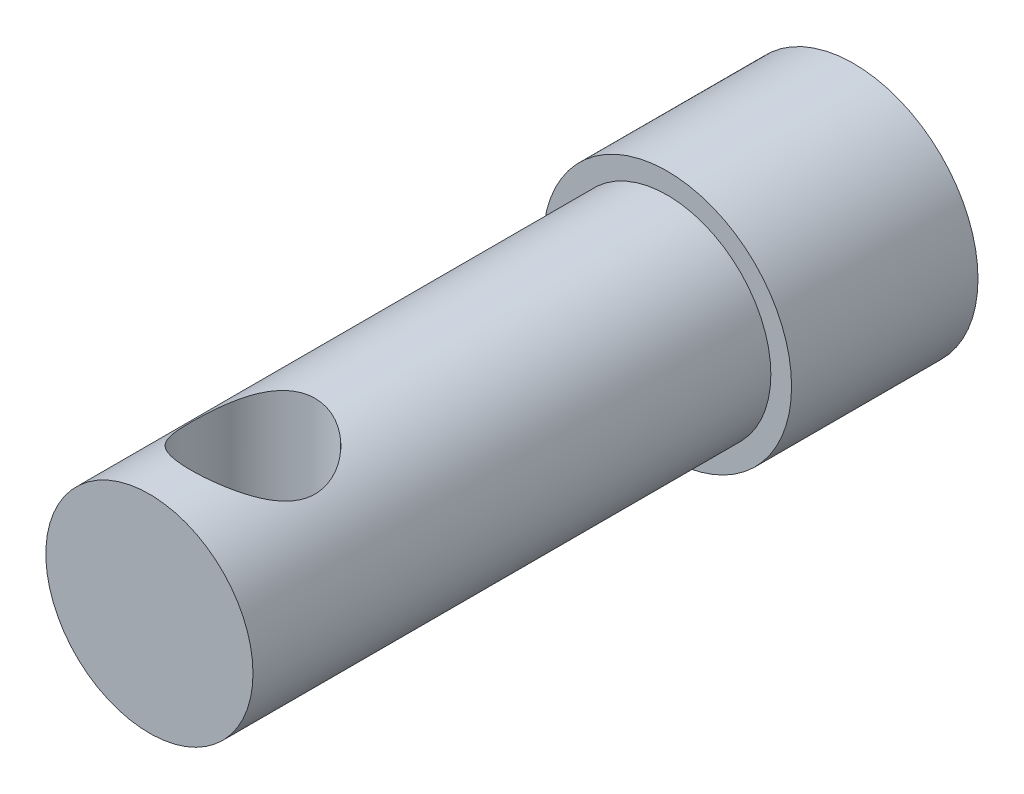
from build123d import *

# Parameters (mm, degrees)
SKETCH_1_R          = 5
EXTRUDE_1_DEPTH     = 34
SKETCH_4_R          = 6
EXTRUDE_2_DEPTH     = 9
CUT_EXTRUDE_1_DEPTH = 8
SKETCH_3_R          = 3
CUT_EXTRUDE_2_DEPTH = 12


with BuildPart() as part:
    # 草图1 → 凸台-拉伸1 (new body)
    with BuildSketch(Plane.XY):
        Circle(SKETCH_1_R)
    extrude(amount=EXTRUDE_1_DEPTH)

    # 草图4 → 凸台-拉伸2 (add)
    with BuildSketch(Plane.XY):
        Circle(SKETCH_4_R)
    extrude(amount=EXTRUDE_2_DEPTH)

    # 草图2 → 切除-拉伸1 (cut)
    with BuildSketch(Plane(origin=(0, 0, 0), x_dir=(-1, 0, 0), z_dir=(0, 0, -1))):
        with BuildLine():
            Line((2.565, -3.165), (-2.565, -3.165))
            ThreePointArc((-2.565, -3.165), (-2.989264069, -2.989264069), (-3.165, -2.565))
            Line((-3.165, -2.565), (-3.165, 2.565))
            ThreePointArc((-3.165, 2.565), (-2.989264069, 2.989264069), (-2.565, 3.165))
            Line((-2.565, 3.165), (2.565, 3.165))
            ThreePointArc((2.565, 3.165), (2.989264069, 2.989264069), (3.165, 2.565))
            Line((3.165, 2.565), (3.165, -2.565))
            ThreePointArc((3.165, -2.565), (2.989264069, -2.989264069), (2.565, -3.165))
        make_face()
    extrude(amount=-CUT_EXTRUDE_1_DEPTH, mode=Mode.SUBTRACT)

    # 草图3 → 切除-拉伸2 (cut, through all)
    with BuildSketch(Plane(origin=(0, -5, 0), x_dir=(-1, 0, 0), z_dir=(0, -1, 0))):
        with Locations((0, -29)):
            Circle(SKETCH_3_R)
    extrude(amount=-CUT_EXTRUDE_2_DEPTH, mode=Mode.SUBTRACT)


solid = part.part
